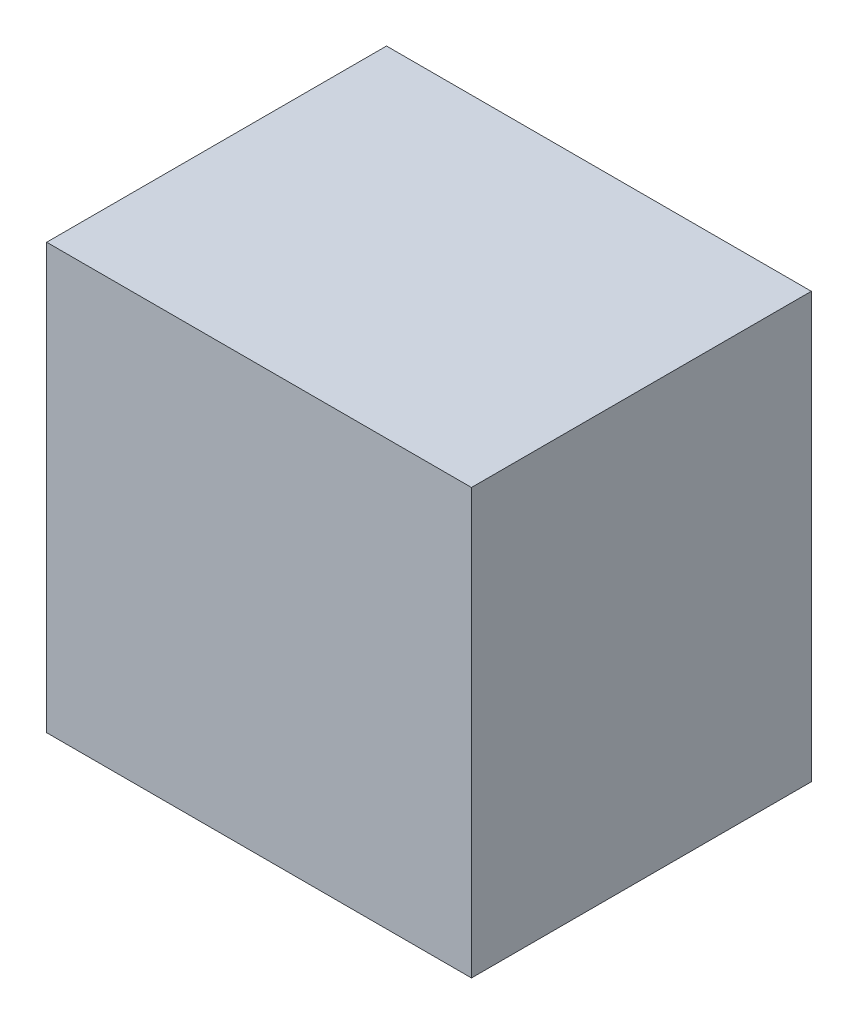
from build123d import *

# Parameters (mm, degrees)
SKETCH1_W           = 100
SKETCH1_H           = 80
BOSS_EXTRUDE1_DEPTH = 100


with BuildPart() as part:
    # Sketch1 → Boss-Extrude1 (new body)
    with BuildSketch(Plane(origin=(0, 0, 0), x_dir=(1, 0, 0), z_dir=(0, 1, 0))):
        with Locations((50, 40)):
            Rectangle(SKETCH1_W, SKETCH1_H)
    extrude(amount=BOSS_EXTRUDE1_DEPTH)


solid = part.part
